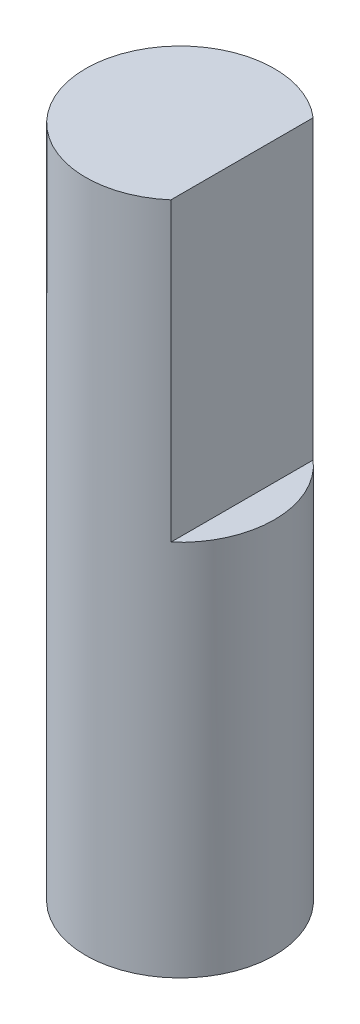
from build123d import *

# Parameters (mm, degrees)
SKETCH1_R               = 3.5
BOSS_EXTRUDE1_DEPTH     = 25
SKETCH2_W               = 1.2
SKETCH2_H               = 11
CUT_EXTRUDE1_DEPTH      = 1
CUT_EXTRUDE1_DEPTH_BACK = 8


with BuildPart() as part:
    # Sketch1 → Boss-Extrude1 (new body)
    with BuildSketch(Plane(origin=(0, 0, 0), x_dir=(1, 0, 0), z_dir=(0, 1, 0))):
        Circle(SKETCH1_R)
    extrude(amount=BOSS_EXTRUDE1_DEPTH)

    # Sketch2 → Cut-Extrude1 (cut, two sides)
    with BuildSketch(Plane(origin=(0, 0, -3.5), x_dir=(-1, 0, 0), z_dir=(0, 0, -1))) as cut_extrude1_sk:
        with Locations((-2.9, 19.5)):
            Rectangle(SKETCH2_W, SKETCH2_H)
    extrude(amount=CUT_EXTRUDE1_DEPTH, mode=Mode.SUBTRACT)
    extrude(cut_extrude1_sk.sketch, amount=-CUT_EXTRUDE1_DEPTH_BACK, mode=Mode.SUBTRACT)


solid = part.part
